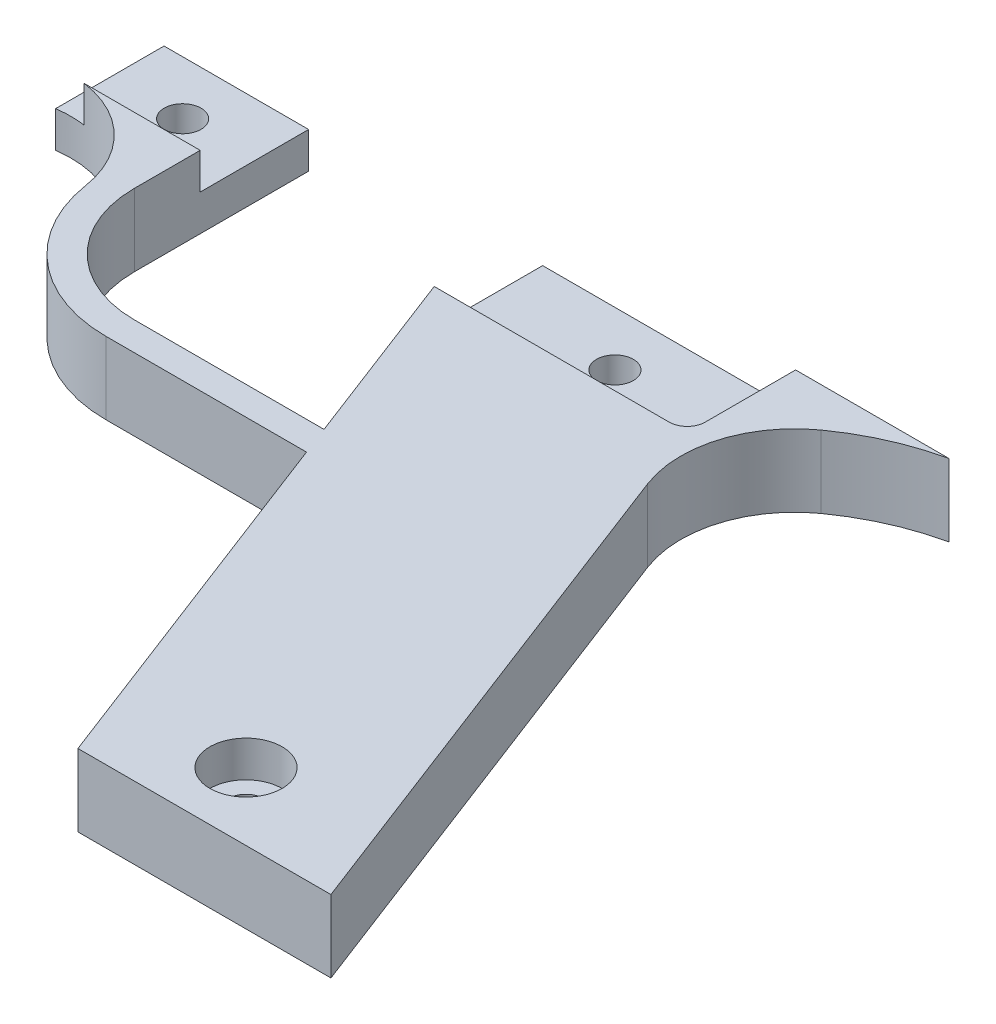
from build123d import *

# Parameters (mm, degrees)
SKETCH1_R           = 3.2385
BOSS_EXTRUDE1_DEPTH = 12.7
SKETCH2_R           = 6.35
SKETCH2_W           = 44.45
SKETCH2_H           = 19.05
CUT_EXTRUDE1_DEPTH  = 6.35
BOSS_EXTRUDE4_DEPTH = 12.7
FILLET1_R           = 20
SKETCH4_R           = 3.2385
BOSS_EXTRUDE5_DEPTH = 12.7
SKETCH5_W           = 25.4
SKETCH5_H           = 19.05
CUT_EXTRUDE2_DEPTH  = 6.35


with BuildPart() as part:
    # Sketch1 → Boss-Extrude1 (new body)
    with BuildSketch(Plane(origin=(0, 0, 0), x_dir=(1, 0, 0), z_dir=(0, 1, 0))):
        Polygon((0, 0), (-39.00058596, 101.6), (-39.00058596, 120.65), (5.44941404, 120.65), (5.44941404, 101.6), (44.45, 0), align=None)
        with Locations((17.673727041, 11.856471417)):
            Circle(SKETCH1_R, mode=Mode.SUBTRACT)
        with Locations((-16.77558596, 111.125)):
            Circle(SKETCH1_R, mode=Mode.SUBTRACT)
    extrude(amount=BOSS_EXTRUDE1_DEPTH)

    # Sketch2 → Cut-Extrude1 (cut)
    with BuildSketch(Plane(origin=(0, 12.7, 0), x_dir=(1, 0, 0), z_dir=(0, 1, 0))):
        with Locations((17.673727041, 11.856471417)):
            Circle(SKETCH2_R)
        with Locations((-16.77558596, 111.125)):
            Rectangle(SKETCH2_W, SKETCH2_H)
    extrude(amount=-CUT_EXTRUDE1_DEPTH, mode=Mode.SUBTRACT)

    # Sketch3 → Boss-Extrude4 (add)
    with BuildSketch(Plane(origin=(0, 12.7, 0), x_dir=(1, 0, 0), z_dir=(0, 1, 0))):
        with BuildLine():
            Line((32.408197765, 120.65), (5.44941404, 120.65))
            Line((5.44941404, 120.65), (5.44941404, 104.775))
            ThreePointArc((5.44941404, 104.775), (4.519478071, 102.52993597), (2.27441404, 101.6))
            Line((2.27441404, 101.6), (5.44941404, 101.6))
            ThreePointArc((5.44941404, 101.6), (16.992497649, 113.865184538), (32.408197765, 120.65))
        make_face()
    extrude(amount=-BOSS_EXTRUDE4_DEPTH)

    # Fillet1
    fillet1_edges = [part.edges().sort_by_distance(p)[0] for p in [
        (5.44941404, 6.35, -101.6),
    ]]
    fillet(fillet1_edges, radius=FILLET1_R)

    # Sketch4 → Boss-Extrude5 (add)
    with BuildSketch(Plane(origin=(0, 0, 0), x_dir=(1, 0, 0), z_dir=(0, 1, 0))):
        with BuildLine():
            Line((-80.27558596, 101.926821939), (-80.27558596, 90.176821939))
            ThreePointArc((-80.27558596, 90.176821939), (-74.417721583, 76.034686315), (-60.27558596, 70.176821939))
            Line((-60.27558596, 70.176821939), (-26.938358036, 70.176821939))
            Line((-26.938358036, 70.176821939), (-25.01903786, 65.176821939))
            Line((-25.01903786, 65.176821939), (-60.27558596, 65.176821939))
            ThreePointArc((-60.27558596, 65.176821939), (-76.539652165, 71.190507118), (-84.979160459, 86.338409901))
            ThreePointArc((-84.979160459, 86.338409901), (-92.17483168, 98.279259247), (-105.67558596, 101.75649972))
            Line((-105.67558596, 101.75649972), (-105.67558596, 120.80649972))
            Line((-105.67558596, 120.80649972), (-80.27558596, 120.80649972))
            Line((-80.27558596, 120.80649972), (-80.27558596, 101.926821939))
        make_face()
        with Locations((-92.97558596, 111.36666083)):
            Circle(SKETCH4_R, mode=Mode.SUBTRACT)
    extrude(amount=BOSS_EXTRUDE5_DEPTH)

    # Sketch5 → Cut-Extrude2 (cut)
    with BuildSketch(Plane(origin=(0, 12.7, 0), x_dir=(1, 0, 0), z_dir=(0, 1, 0))):
        with Locations((-92.97558596, 111.28149972)):
            Rectangle(SKETCH5_W, SKETCH5_H)
    extrude(amount=-CUT_EXTRUDE2_DEPTH, mode=Mode.SUBTRACT)


solid = part.part
